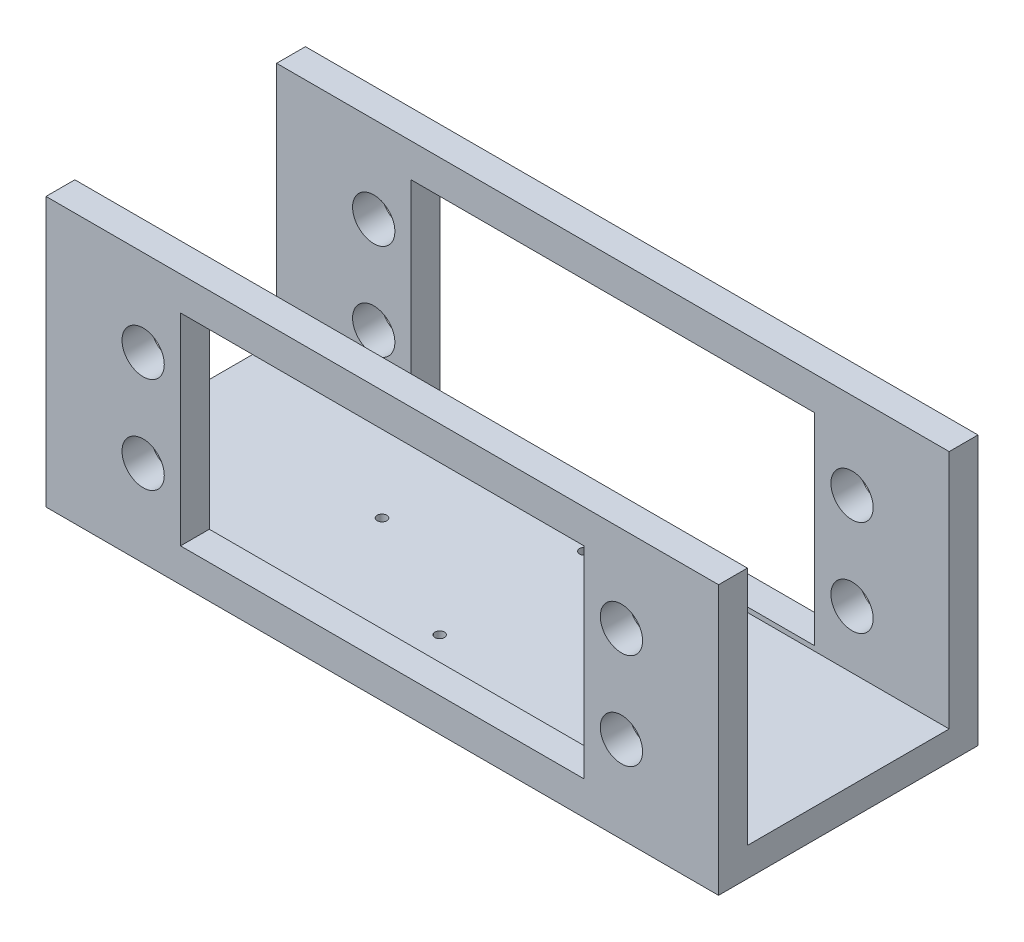
from build123d import *

# Parameters (mm, degrees)
SKETCH1_W           = 70
SKETCH1_H           = 27
SKETCH1_R           = 0.5
BOSS_EXTRUDE2_DEPTH = 3
SKETCH2_W           = 70
SKETCH2_H           = 3
BOSS_EXTRUDE3_DEPTH = 25
SKETCH3_R           = 2.2
SKETCH3_W           = 42
SKETCH3_H           = 21
CUT_EXTRUDE1_DEPTH  = 25


with BuildPart() as part:
    # Sketch1 → Boss-Extrude2 (new body)
    with BuildSketch(Plane(origin=(0, 0, 0), x_dir=(1, 0, 0), z_dir=(0, 1, 0))):
        Rectangle(SKETCH1_W, SKETCH1_H)
        with Locations((-13.53, 0)):
            Circle(SKETCH1_R, mode=Mode.SUBTRACT)
        with Locations((0, 7.53)):
            Circle(SKETCH1_R, mode=Mode.SUBTRACT)
        with Locations((0, -7.53)):
            Circle(SKETCH1_R, mode=Mode.SUBTRACT)
        with Locations((13.53, 0)):
            Circle(SKETCH1_R, mode=Mode.SUBTRACT)
    extrude(amount=BOSS_EXTRUDE2_DEPTH)

    # Sketch2 → Boss-Extrude3 (add)
    with BuildSketch(Plane(origin=(0, 3, 0), x_dir=(1, 0, 0), z_dir=(0, 1, 0))):
        with Locations((0, -12)):
            Rectangle(SKETCH2_W, SKETCH2_H)
    extrude(amount=BOSS_EXTRUDE3_DEPTH)

    # Sketch3 → Cut-Extrude1 (cut)
    with BuildSketch(Plane.XY.offset(13.5)):
        with Locations((-24.89, 9)):
            Circle(SKETCH3_R)
        with Locations((-24.89, 19)):
            Circle(SKETCH3_R)
        with Locations((0, 14)):
            Rectangle(SKETCH3_W, SKETCH3_H)
        with Locations((24.89, 19)):
            Circle(SKETCH3_R)
        with Locations((24.89, 9)):
            Circle(SKETCH3_R)
    extrude(amount=-CUT_EXTRUDE1_DEPTH, mode=Mode.SUBTRACT)

    # Mirror1: part across plane


with BuildPart() as part_1:
    add(part.part)
    add(part.part.mirror(Plane.XY))


solid = part_1.part
